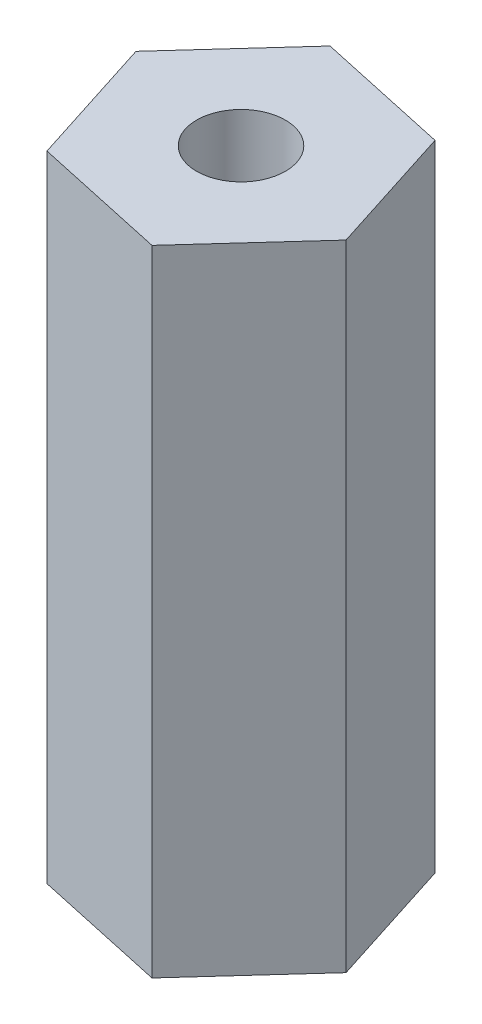
from build123d import *

# Parameters (mm, degrees)
BOSS_EXTRUDE1_DEPTH       = 12.7
TAP_DRILL_FOR_2_56_TAP1_D = 1.778


with BuildPart() as part:
    # Sketch1 → Boss-Extrude1 (new body)
    with BuildSketch(Plane(origin=(0, 0, 0), x_dir=(1, 0, 0), z_dir=(0, 1, 0))):
        Polygon((1.849601737, 2.03456191), (-0.837181432, 2.619083046), (-2.686783168, 0.584521136), (-1.849601737, -2.03456191), (0.837181432, -2.619083046), (2.686783168, -0.584521136), align=None)
    extrude(amount=BOSS_EXTRUDE1_DEPTH)

    # Tap Drill for #2-56 Tap1 (through all)
    with Locations(Plane(origin=(0, 12.7, 0), x_dir=(1, 0, 0), z_dir=(0, 1, 0))):
        with Locations((0, 0)):
            Hole(TAP_DRILL_FOR_2_56_TAP1_D / 2)


solid = part.part
